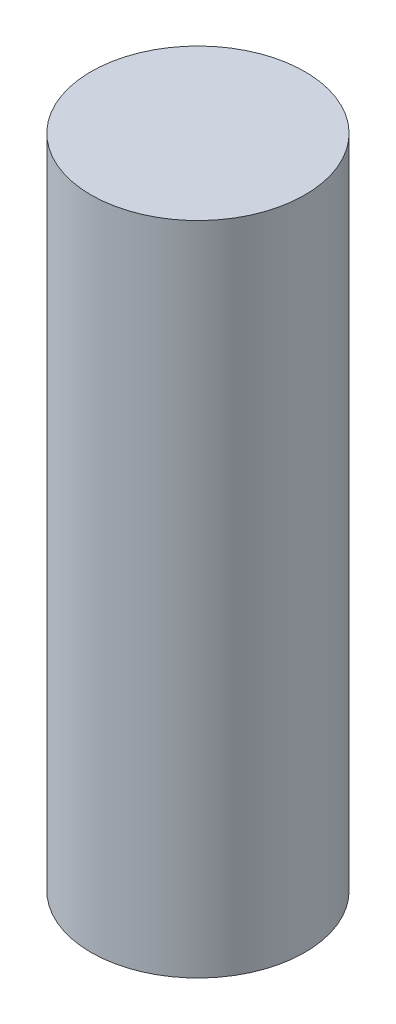
from build123d import *

# Parameters (mm, degrees)
SKETCH_1_R      = 2.2
EXTRUDE_1_DEPTH = 13.5


with BuildPart() as part:
    # 스케치1 → 보스-돌출1 (new body)
    with BuildSketch(Plane(origin=(0, 0, 0), x_dir=(1, 0, 0), z_dir=(0, 1, 0))):
        Circle(SKETCH_1_R)
    extrude(amount=EXTRUDE_1_DEPTH)


solid = part.part
